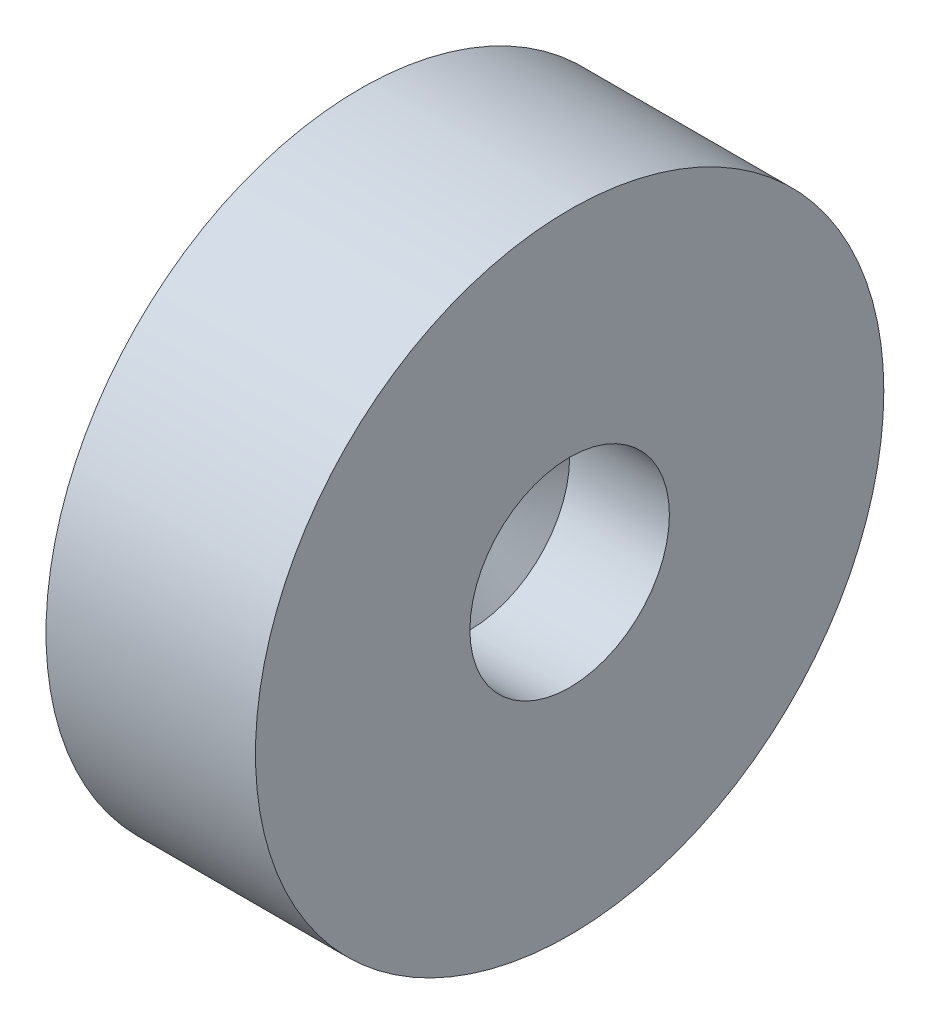
from build123d import *

# Parameters (mm, degrees)
SKETCH1_R           = 15
BOSS_EXTRUDE1_DEPTH = 10
SKETCH2_W           = 15
SKETCH2_H           = 15
CUT_EXTRUDE1_DEPTH  = 3
SKETCH3_R           = 4.7625
CUT_EXTRUDE2_DEPTH  = 4.7625


with BuildPart() as part:
    # Sketch1 → Boss-Extrude1 (new body)
    with BuildSketch(Plane(origin=(0, 0, 0), x_dir=(0, 0, -1), z_dir=(1, 0, 0))):
        Circle(SKETCH1_R)
    extrude(amount=BOSS_EXTRUDE1_DEPTH)

    # Sketch2 → Cut-Extrude1 (cut)
    with BuildSketch(Plane.ZY):
        Rectangle(SKETCH2_W, SKETCH2_H)
    extrude(amount=-CUT_EXTRUDE1_DEPTH, mode=Mode.SUBTRACT)

    # Sketch3 → Cut-Extrude2 (cut)
    with BuildSketch(Plane(origin=(10, 0, 0), x_dir=(0, 0, -1), z_dir=(1, 0, 0))):
        Circle(SKETCH3_R)
    extrude(amount=-CUT_EXTRUDE2_DEPTH, mode=Mode.SUBTRACT)

    # Sketch4 → Cut-Revolve1 (revolve, cut)
    with BuildSketch(Plane.XY):
        Polygon((5.2375, 4.7625), (3, 1.25), (3, 0), (5.2375, 0), align=None)
    revolve(axis=Axis((5.2375, 0, 0), (1, 0, 0)), mode=Mode.SUBTRACT)


solid = part.part
